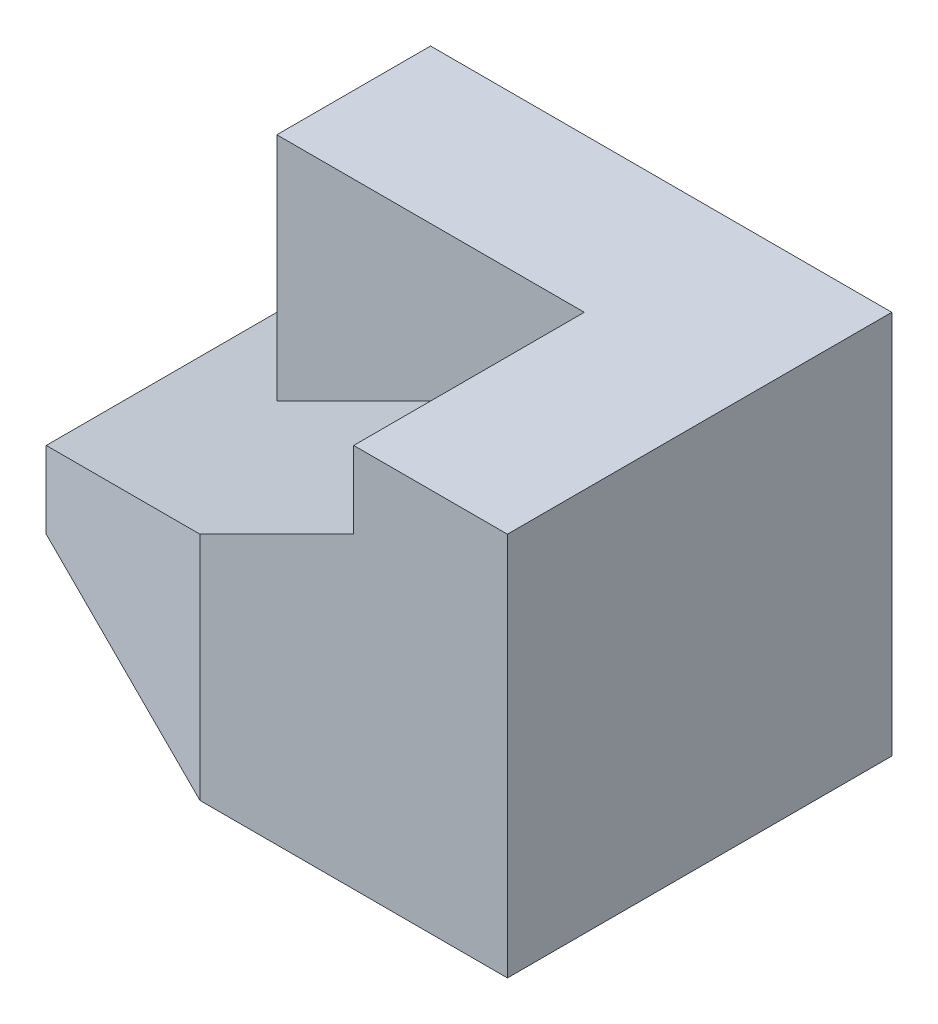
from build123d import *

# Parameters (mm, degrees)
SKETCH1_W           = 80
SKETCH1_H           = 50
BOSS_EXTRUDE1_DEPTH = 50
CUT_EXTRUDE1_DEPTH  = 30
SKETCH3_W           = 20
SKETCH3_H           = 40
CUT_EXTRUDE2_DEPTH  = 103
CUT_EXTRUDE3_DEPTH  = 103
SKETCH5_W           = 30
SKETCH5_H           = 20
CUT_EXTRUDE4_DEPTH  = 103
CUT_EXTRUDE6_DEPTH  = 103
BOSS_EXTRUDE2_DEPTH = 15
BOSS_EXTRUDE3_DEPTH = 15
SKETCH10_W          = 83.848824186
SKETCH10_H          = 50
CUT_EXTRUDE7_DEPTH  = 15
BOSS_EXTRUDE6_DEPTH = 37


with BuildPart() as part:
    # Sketch1 → Boss-Extrude1 (new body)
    with BuildSketch(Plane.XY):
        with Locations((40, 25)):
            Rectangle(SKETCH1_W, SKETCH1_H)
    extrude(amount=-BOSS_EXTRUDE1_DEPTH)

    # Sketch2 → Cut-Extrude1 (cut)
    with BuildSketch(Plane.XY):
        Polygon((60, 40), (60, 50), (40, 50), (40, 30), align=None)
    extrude(amount=-CUT_EXTRUDE1_DEPTH, mode=Mode.SUBTRACT)

    # Sketch3 → Cut-Extrude2 (cut)
    with BuildSketch(Plane(origin=(0, 0, -50), x_dir=(-1, 0, 0), z_dir=(0, 0, -1))):
        with Locations((-10, 30)):
            Rectangle(SKETCH3_W, SKETCH3_H)
    extrude(amount=-CUT_EXTRUDE2_DEPTH, mode=Mode.SUBTRACT)

    # Sketch4 → Cut-Extrude3 (cut)
    with BuildSketch(Plane(origin=(0, 0, 0), x_dir=(-1, 0, 0), z_dir=(0, -1, 0))):
        Polygon((0, 0), (0, 20), (-40, 0), align=None)
    extrude(amount=-CUT_EXTRUDE3_DEPTH, mode=Mode.SUBTRACT)

    # Sketch5 → Cut-Extrude4 (cut)
    with BuildSketch(Plane(origin=(40, 0, 0), x_dir=(0, 0, -1), z_dir=(1, 0, 0))):
        with Locations((15, 40)):
            Rectangle(SKETCH5_W, SKETCH5_H)
    extrude(amount=-CUT_EXTRUDE4_DEPTH, mode=Mode.SUBTRACT)

    # Sketch6 → Cut-Extrude6 (cut)
    with BuildSketch(Plane(origin=(-4, 8, 0), x_dir=(-0.894427191, -0.447213595, 0), z_dir=(0.447213595, -0.894427191, 0))):
        Polygon((-71.55417528, 30), (-4.472135955, 35), (0, 0), (-71.55417528, 0), align=None)
    extrude(amount=-CUT_EXTRUDE6_DEPTH, mode=Mode.SUBTRACT)

    # Sketch7 → Boss-Extrude2 (add)
    with BuildSketch(Plane(origin=(-4, 8, 0), x_dir=(-0.894427191, -0.447213595, 0), z_dir=(0.447213595, -0.894427191, 0))):
        Polygon((-26.83281573, 33.333333333), (-4.472135955, 50), (-4.472135955, 20), (-26.83281573, 10), align=None)
        Polygon((-26.83281573, 50), (-4.472135955, 50), (-26.83281573, 33.333333333), align=None)
    extrude(amount=BOSS_EXTRUDE2_DEPTH)

    # Sketch8 → Boss-Extrude3 (add)
    with BuildSketch(Plane(origin=(8, 0, -16), x_dir=(0.894427191, 0, 0.447213595), z_dir=(-0.447213595, 0, 0.894427191))):
        Polygon((13.416407865, 10), (-8.94427191, 10), (13.416407865, 20), align=None)
    extrude(amount=-BOSS_EXTRUDE3_DEPTH)

    # Sketch10 → Cut-Extrude7 (cut)
    with BuildSketch(Plane(origin=(0, 0, 0), x_dir=(-1, 0, 0), z_dir=(0, -1, 0))):
        with Locations((-38.075587907, 25)):
            Rectangle(SKETCH10_W, SKETCH10_H)
    extrude(amount=CUT_EXTRUDE7_DEPTH, mode=Mode.SUBTRACT)

    # Sketch15 → Boss-Extrude6 (add)
    with BuildSketch(Plane(origin=(0, 50, 0), x_dir=(1, 0, 0), z_dir=(0, 1, 0))):
        Polygon((55, 30), (60, 30), (62.90753881, 30), (62.90753881, 35.567139934), (20, 35.567139934), (20, 32.333333333), align=None)
        Polygon((20, 30), (55, 30), (20, 32.333333333), align=None)
    extrude(amount=-BOSS_EXTRUDE6_DEPTH)


solid = part.part
